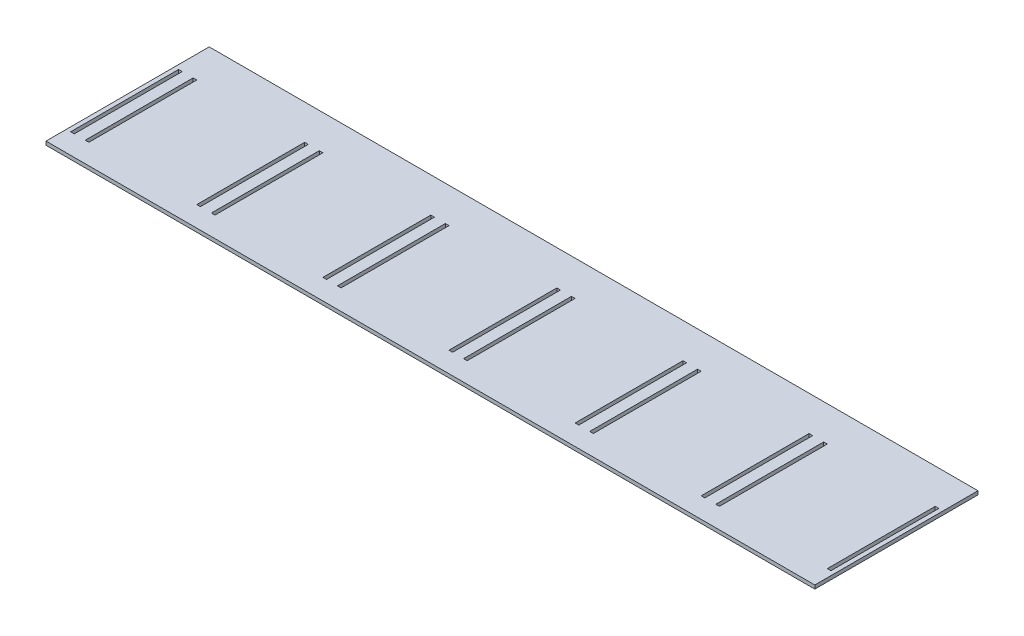
from build123d import *

# Parameters (mm, degrees)
SKETCH2_W           = 424
SKETCH2_H           = 90
SKETCH2_W_2         = 2
SKETCH2_H_2         = 59.5
BOSS_EXTRUDE1_DEPTH = 2


with BuildPart() as part:
    # Sketch2 → Boss-Extrude1 (new body)
    with BuildSketch(Plane(origin=(0, 0, 0), x_dir=(1, 0, 0), z_dir=(0, 1, 0))):
        with Locations((282.3665082, -7.414833114)):
            Rectangle(SKETCH2_W, SKETCH2_H)
        with Locations((73.7165082, -11.414833114)):
            Rectangle(SKETCH2_W_2, SKETCH2_H_2, mode=Mode.SUBTRACT)
        with Locations((143.2665082, -11.414833114)):
            Rectangle(SKETCH2_W_2, SKETCH2_H_2, mode=Mode.SUBTRACT)
        with Locations((81.7665082, -11.414833114)):
            Rectangle(SKETCH2_W_2, SKETCH2_H_2, mode=Mode.SUBTRACT)
        with Locations((151.3165082, -11.414833114)):
            Rectangle(SKETCH2_W_2, SKETCH2_H_2, mode=Mode.SUBTRACT)
        with Locations((212.8165082, -11.414833114)):
            Rectangle(SKETCH2_W_2, SKETCH2_H_2, mode=Mode.SUBTRACT)
        with Locations((220.8665082, -11.414833114)):
            Rectangle(SKETCH2_W_2, SKETCH2_H_2, mode=Mode.SUBTRACT)
        with Locations((282.3665082, -11.414833114)):
            Rectangle(SKETCH2_W_2, SKETCH2_H_2, mode=Mode.SUBTRACT)
        with Locations((290.4165082, -11.414833114)):
            Rectangle(SKETCH2_W_2, SKETCH2_H_2, mode=Mode.SUBTRACT)
        with Locations((351.9165082, -11.414833114)):
            Rectangle(SKETCH2_W_2, SKETCH2_H_2, mode=Mode.SUBTRACT)
        with Locations((359.9665082, -11.414833114)):
            Rectangle(SKETCH2_W_2, SKETCH2_H_2, mode=Mode.SUBTRACT)
        with Locations((421.4665082, -11.414833114)):
            Rectangle(SKETCH2_W_2, SKETCH2_H_2, mode=Mode.SUBTRACT)
        with Locations((429.5165082, -11.414833114)):
            Rectangle(SKETCH2_W_2, SKETCH2_H_2, mode=Mode.SUBTRACT)
        with Locations((491.0165082, -11.414833114)):
            Rectangle(SKETCH2_W_2, SKETCH2_H_2, mode=Mode.SUBTRACT)
    extrude(amount=BOSS_EXTRUDE1_DEPTH)


solid = part.part
